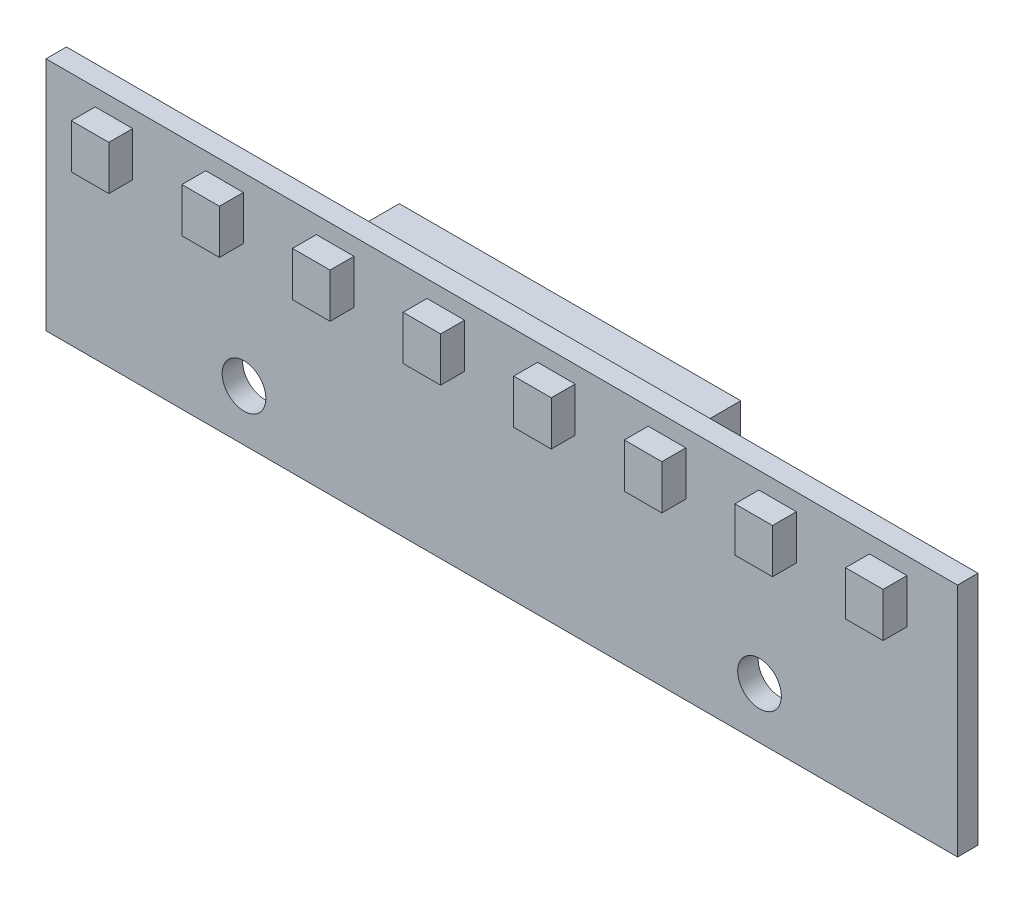
from build123d import *

# Parameters (mm, degrees)
SKETCH1_W           = 66.75
SKETCH1_H           = 17.25
BOSS_EXTRUDE1_DEPTH = 1.5
SKETCH2_W           = 2.75
SKETCH2_H           = 3.25
BOSS_EXTRUDE2_DEPTH = 1.75
LPATTERN1_COUNT     = 8
LPATTERN1_PITCH     = 8.1
SKETCH3_R           = 1.6
CUT_EXTRUDE1_DEPTH  = 69.965117995
SKETCH4_W           = 25
SKETCH4_H           = 16
BOSS_EXTRUDE3_DEPTH = 3.5


with BuildPart() as part:
    # Sketch1 → Boss-Extrude1 (new body)
    with BuildSketch(Plane.XY):
        with Locations((33.375, 8.625)):
            Rectangle(SKETCH1_W, SKETCH1_H)
    extrude(amount=BOSS_EXTRUDE1_DEPTH)

    # Sketch2 → Boss-Extrude2 (add)
    with BuildSketch(Plane.XY.offset(1.5)):
        with Locations((4.975, 14.375)):
            Rectangle(SKETCH2_W, SKETCH2_H)
    boss_extrude2 = extrude(amount=BOSS_EXTRUDE2_DEPTH)

    # LPattern1: Boss-Extrude2 ×8
    with Locations(*[(i * LPATTERN1_PITCH, 0, 0) for i in range(1, LPATTERN1_COUNT)]):
        add(boss_extrude2)

    # Sketch3 → Cut-Extrude1 (cut, through all)
    with BuildSketch(Plane.XY.offset(1.5)):
        with Locations((14.5, 3.75)):
            Circle(SKETCH3_R)
    cut_extrude1 = extrude(amount=-CUT_EXTRUDE1_DEPTH, mode=Mode.SUBTRACT)

    # Mirror1: Cut-Extrude1 across plane
    add(cut_extrude1.mirror(Plane.ZY.offset(-33.375)), mode=Mode.SUBTRACT)

    # Sketch4 → Boss-Extrude3 (add)
    with BuildSketch(Plane(origin=(0, 0, 0), x_dir=(-1, 0, 0), z_dir=(0, 0, -1))):
        with Locations((-33.375, 8)):
            Rectangle(SKETCH4_W, SKETCH4_H)
    extrude(amount=BOSS_EXTRUDE3_DEPTH)


solid = part.part
